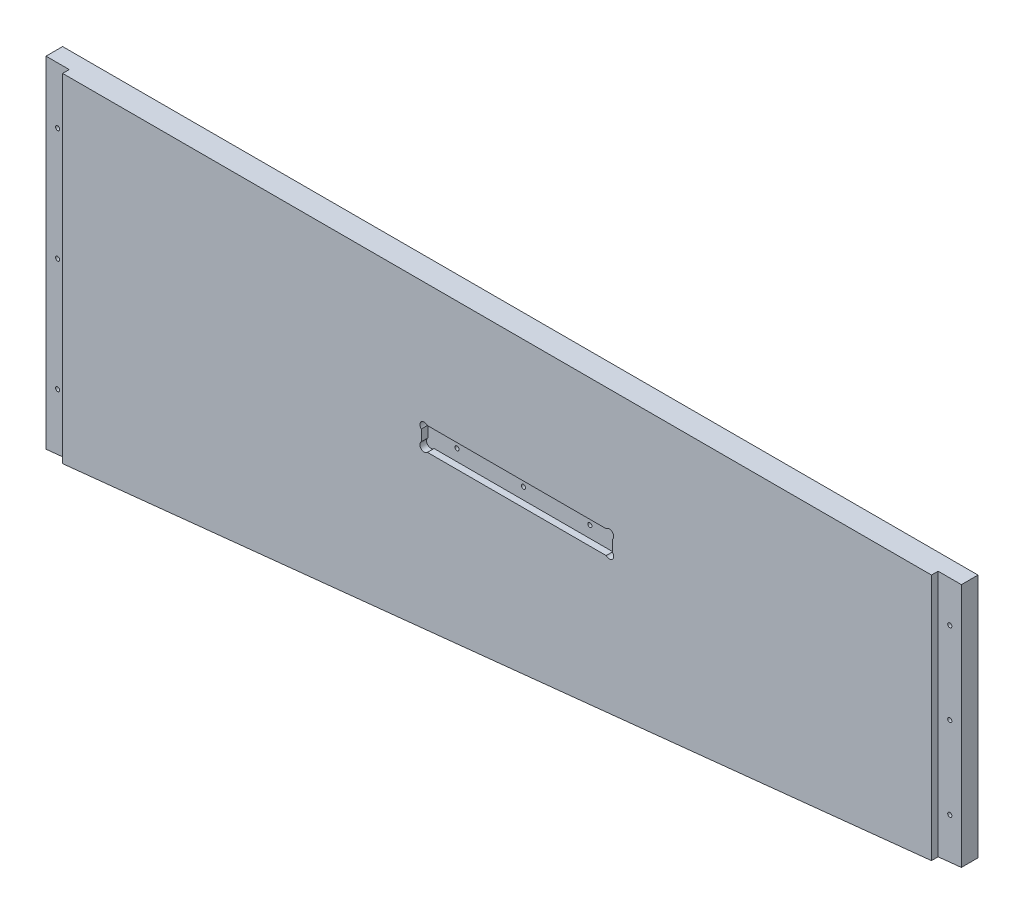
from build123d import *

# Parameters (mm, degrees)
EXTRUDE1_DEPTH     = 17.78
SKETCH3_R          = 1.5875
CUT_EXTRUDE1_DEPTH = 17.78
SKETCH4_W          = 17.78
SKETCH4_H          = 260.35
SKETCH4_H_2        = 189.179603175
SKETCH4_W_2        = 146.050000002
SKETCH4_H_3        = 17.780000002
CUT_EXTRUDE2_DEPTH = 5.08
SKETCH6_R          = 3.302
CUT_EXTRUDE3_DEPTH = 5.08


with BuildPart() as part:
    # Sketch2 → Extrude1 (new body)
    with BuildSketch(Plane.XY):
        Polygon((857.25, -5502.275), (857.25, -5314.95), (157.1625, -5314.95), (157.1625, -5575.3), align=None)
    extrude(amount=-EXTRUDE1_DEPTH)

    # Sketch3 → Cut-Extrude1 (cut)
    with BuildSketch(Plane.XY):
        with Locations((166.0525, -5531.135582009)):
            Circle(SKETCH3_R)
        with Locations((166.0525, -5444.661349205)):
            Circle(SKETCH3_R)
        with Locations((166.0525, -5358.187116401)):
            Circle(SKETCH3_R)
        with Locations((848.36, -5471.826917991)):
            Circle(SKETCH3_R)
        with Locations((848.36, -5409.076150795)):
            Circle(SKETCH3_R)
        with Locations((848.36, -5346.325383599)):
            Circle(SKETCH3_R)
        with Locations((573.0875, -5417.566)):
            Circle(SKETCH3_R)
        with Locations((522.2875, -5417.566)):
            Circle(SKETCH3_R)
        with Locations((471.4875, -5417.566)):
            Circle(SKETCH3_R)
    extrude(amount=-CUT_EXTRUDE1_DEPTH, mode=Mode.SUBTRACT)

    # Sketch4 → Cut-Extrude2 (cut)
    with BuildSketch(Plane.XY):
        with Locations((166.0525, -5445.125)):
            Rectangle(SKETCH4_W, SKETCH4_H)
        with Locations((848.36, -5409.539801588)):
            Rectangle(SKETCH4_W, SKETCH4_H_2)
        with Locations((522.2875, -5417.566)):
            Rectangle(SKETCH4_W_2, SKETCH4_H_3)
    extrude(amount=-CUT_EXTRUDE2_DEPTH, mode=Mode.SUBTRACT)

    # Sketch6 → Cut-Extrude3 (cut)
    with BuildSketch(Plane.XY):
        with Locations((451.507564029, -5410.921064029)):
            Circle(SKETCH6_R)
        with Locations((451.507564029, -5424.210935971)):
            Circle(SKETCH6_R)
        with Locations((593.067435971, -5424.210935971)):
            Circle(SKETCH6_R)
        with Locations((593.067435971, -5410.921064029)):
            Circle(SKETCH6_R)
    extrude(amount=-CUT_EXTRUDE3_DEPTH, mode=Mode.SUBTRACT)


solid = part.part
